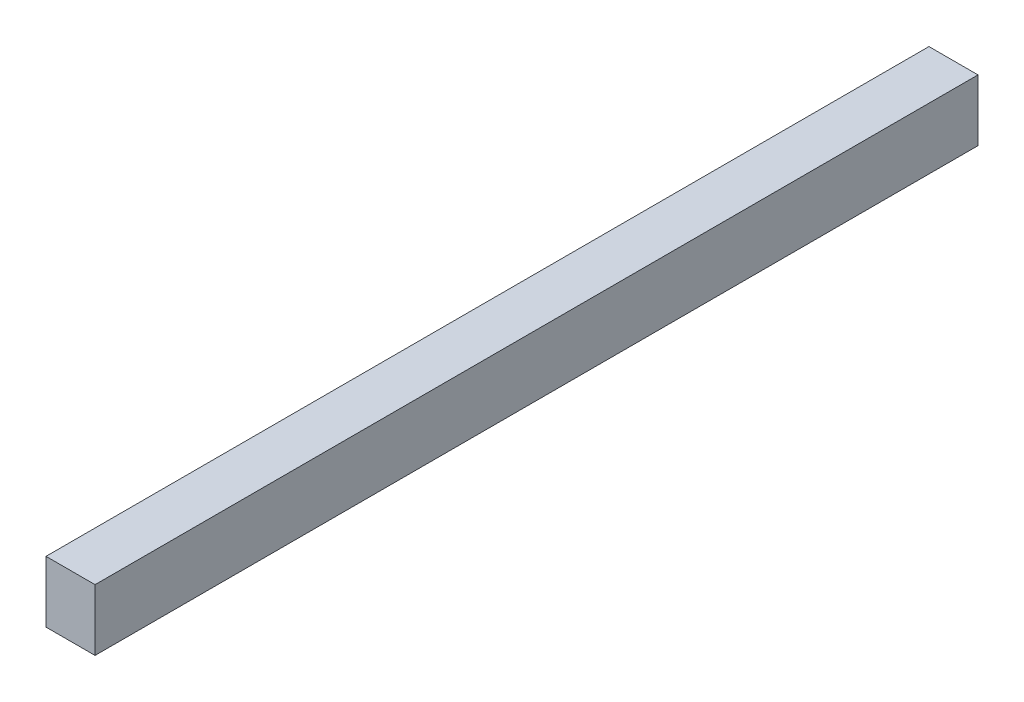
from build123d import *

# Parameters (mm, degrees)
SKETCH1_W           = 25.4
SKETCH1_H           = 31.75
BOSS_EXTRUDE1_DEPTH = 457.2


with BuildPart() as part:
    # Sketch1 → Boss-Extrude1 (new body)
    with BuildSketch(Plane.XY):
        Rectangle(SKETCH1_W, SKETCH1_H)
    extrude(amount=BOSS_EXTRUDE1_DEPTH)


solid = part.part
